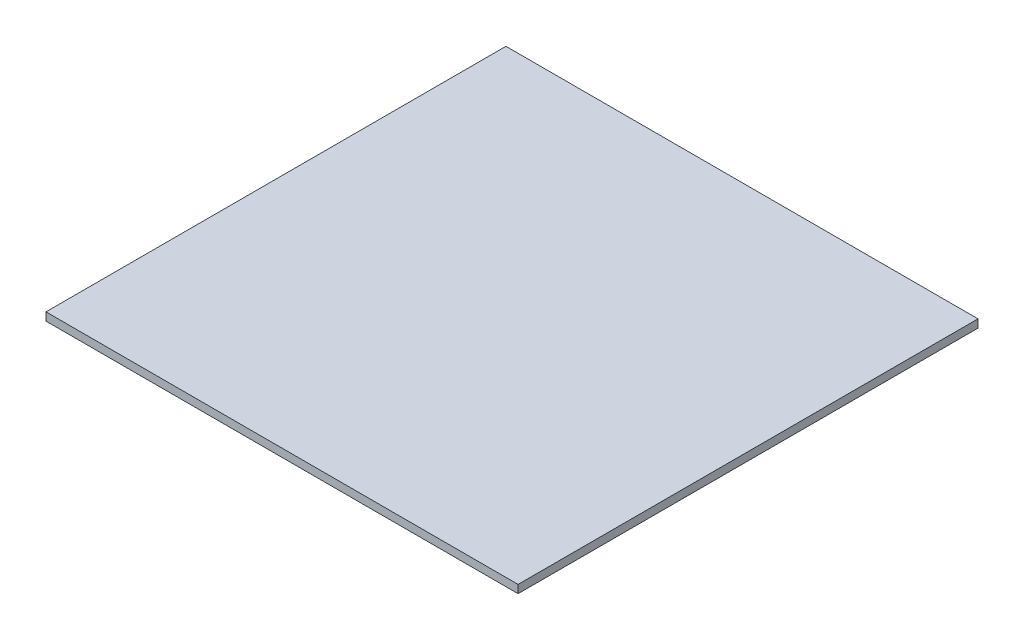
from build123d import *

# Parameters (mm, degrees)
SKETCH1_W      = 5850
SKETCH1_H      = 5700
EXTRUDE1_DEPTH = 100


with BuildPart() as part:
    # Sketch1 → Extrude1 (new body)
    with BuildSketch(Plane(origin=(0, 20425, 0), x_dir=(-1, 0, 0), z_dir=(0, 1, 0))):
        with Locations((-7975, 2850)):
            Rectangle(SKETCH1_W, SKETCH1_H)
    extrude(amount=EXTRUDE1_DEPTH)


solid = part.part
